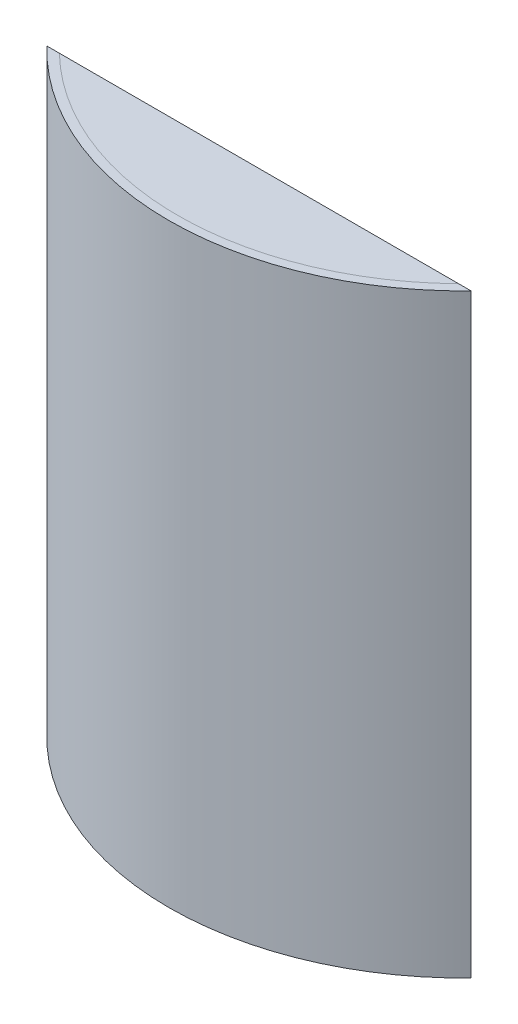
from build123d import *

# Parameters (mm, degrees)
BOSS_EXTRUDE3_DEPTH = 202
BOSS_EXTRUDE4_DEPTH = 2
BOSS_EXTRUDE5_DEPTH = 2


with BuildPart() as part:
    # Sketch1 → Boss-Extrude3 (new body)
    with BuildSketch(Plane(origin=(0, 0, 0), x_dir=(1, 0, 0), z_dir=(0, 1, 0))):
        with BuildLine():
            Line((-67.771675499, -69.397406292), (-72, -69.397406292))
            ThreePointArc((-72, -69.397406292), (0, -100), (72, -69.397406292))
            Line((72, -69.397406292), (67.771675499, -69.397406292))
            ThreePointArc((67.771675499, -69.397406292), (66.18137474, -70.915623367), (64.557072132, -72.397406292))
            ThreePointArc((64.557072132, -72.397406292), (0, -97), (-64.557072132, -72.397406292))
            ThreePointArc((-64.557072132, -72.397406292), (-66.18137474, -70.915623367), (-67.771675499, -69.397406292))
        make_face()
    extrude(amount=BOSS_EXTRUDE3_DEPTH)

    # Sketch1_6 → Boss-Extrude4 (add)
    with BuildSketch(Plane(origin=(0, 0, 0), x_dir=(1, 0, 0), z_dir=(0, 1, 0))):
        with BuildLine():
            Line((-72, -69.397406292), (72, -69.397406292))
            ThreePointArc((72, -69.397406292), (0, -100), (-72, -69.397406292))
        make_face()
    extrude(amount=BOSS_EXTRUDE4_DEPTH)


with BuildPart() as body_2:
    # Sketch7 → Boss-Extrude5 (new body)
    with BuildSketch(Plane(origin=(0, 202, 0), x_dir=(1, 0, 0), z_dir=(0, 1, 0))):
        with BuildLine():
            ThreePointArc((-67.771675499, -69.397406292), (0, -97), (67.771675499, -69.397406292))
            Line((67.771675499, -69.397406292), (-67.771675499, -69.397406292))
        make_face()
    extrude(amount=-BOSS_EXTRUDE5_DEPTH)


solid = Compound([part.part, body_2.part])
